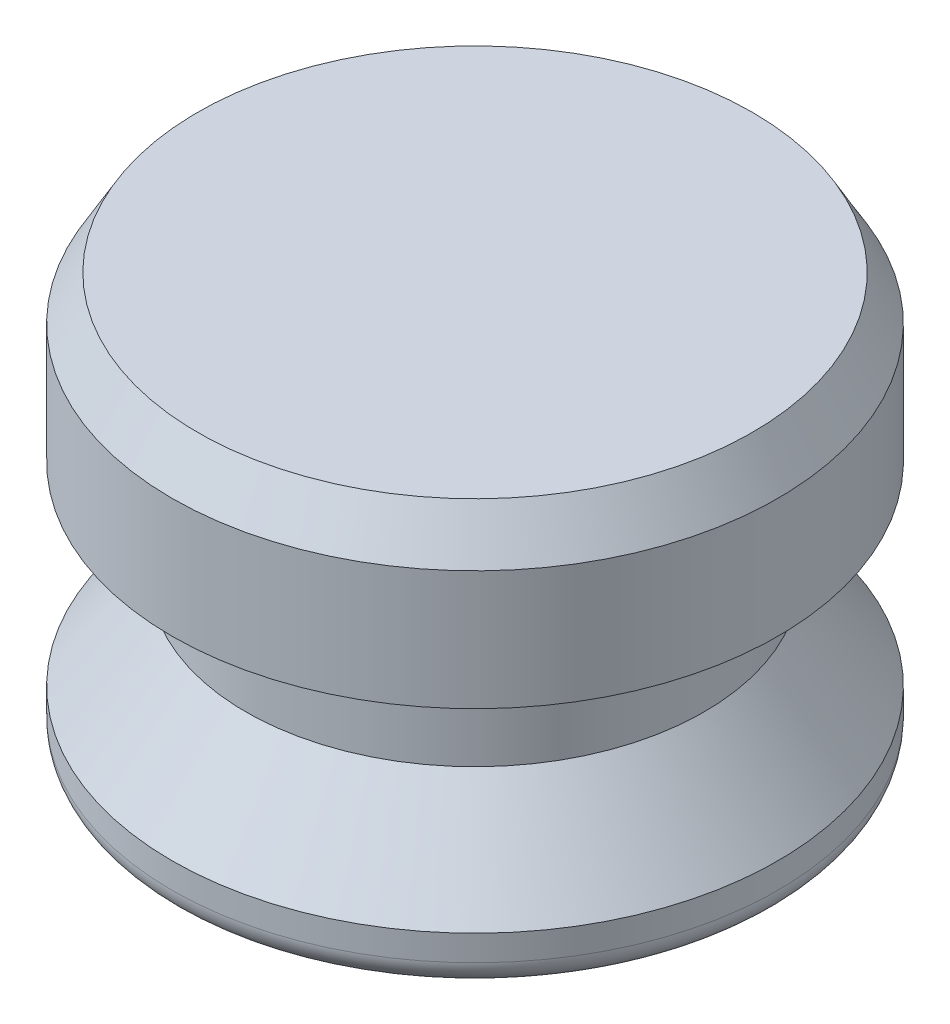
from build123d import *

# Parameters (mm, degrees)
FILLET1_R      = 0.79375
CHAMFER1_SIZE  = 0.79375
CHAMFER1_SIZE2 = 1.374815329


with BuildPart() as part:
    # Sketch1 → Revolve1 (revolve)
    with BuildSketch(Plane.XY):
        Polygon((0, 0), (-9.398, 0), (-9.398, 1.5875), (-7.112, 4.445), (-7.112, 7.62), (-9.398, 7.62), (-9.398, 12.7), (0, 12.7), align=None)
    revolve(axis=Axis((0, 0, 0), (0, 1, 0)))

    # Fillet1
    fillet1_edges = [part.edges().sort_by_distance(p)[0] for p in [
        (9.398, 0, 0),
    ]]
    fillet(fillet1_edges, radius=FILLET1_R)

    # Chamfer1
    chamfer1_edges = [part.edges().sort_by_distance(p)[0] for p in [
        (9.398, 12.7, 0),
    ]]
    chamfer1_side = [part.faces().sort_by_distance(p)[0] for p in [
        (0, 12.7, 0),
    ]]
    chamfer(chamfer1_edges, length=CHAMFER1_SIZE, length2=CHAMFER1_SIZE2, reference=chamfer1_side[0])


solid = part.part
